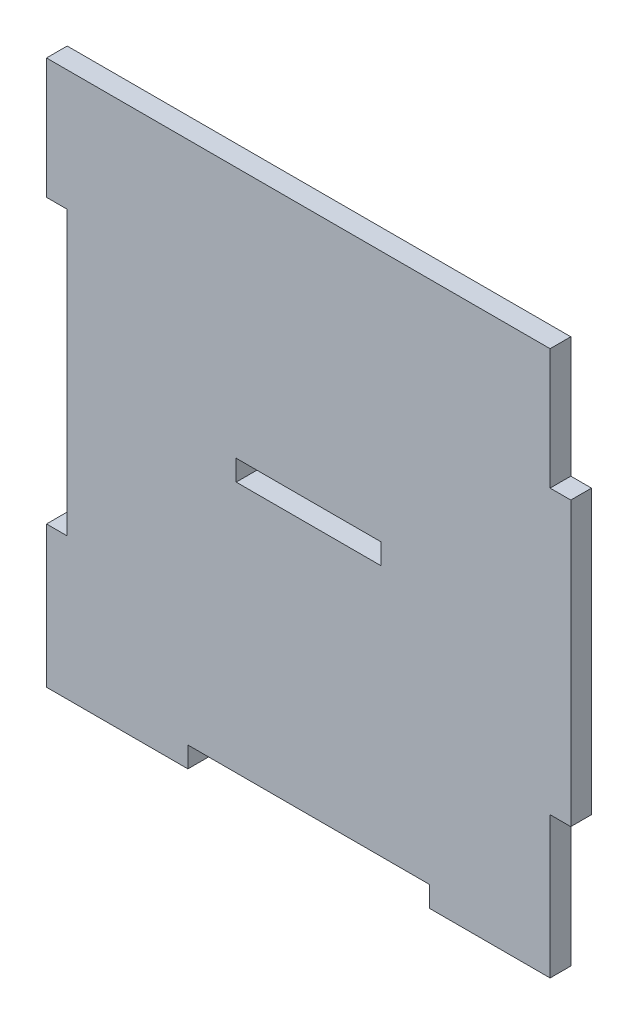
from build123d import *

# Parameters (mm, degrees)
BOSS_EXTRUDE1_DEPTH = 3
SKETCH2_W           = 21
SKETCH2_H           = 3
CUT_EXTRUDE1_DEPTH  = 3


with BuildPart() as part:
    # Sketch1 → Boss-Extrude1 (new body)
    with BuildSketch(Plane.XY):
        Polygon((-35, 38), (-17.5, 38), (17.5, 38), (35, 38), (35, 20.5), (38, 20.5), (38, -20.5), (35, -20.5), (35, -38), (35, -41), (17.5, -41), (17.5, -38), (-17.5, -38), (-17.5, -41), (-35, -41), (-38, -41), (-38, -38), (-38, -20.5), (-35, -20.5), (-35, 20.5), (-38, 20.5), (-38, 38), align=None)
    extrude(amount=BOSS_EXTRUDE1_DEPTH)

    # Sketch2 → Cut-Extrude1 (cut)
    with BuildSketch(Plane.XY.offset(3)):
        Rectangle(SKETCH2_W, SKETCH2_H)
    extrude(amount=-CUT_EXTRUDE1_DEPTH, mode=Mode.SUBTRACT)


solid = part.part
